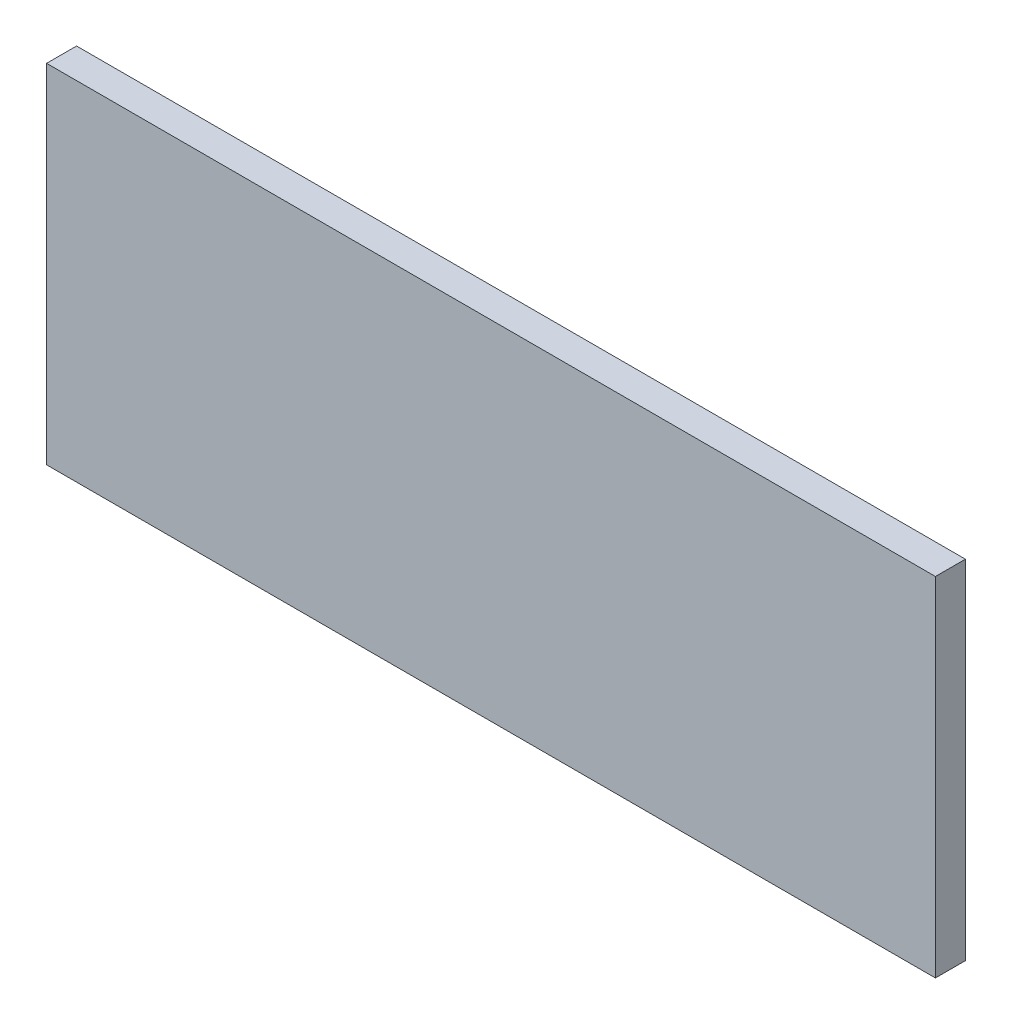
from build123d import *

# Parameters (mm, degrees)
ESBO_O1_W                = 296.5
ESBO_O1_H                = 116
RESSALTO_EXTRUS_O1_DEPTH = 5


with BuildPart() as part:
    # Esboço1 → Ressalto-extrusão1 (new body, symmetric)
    with BuildSketch(Plane.XY):
        Rectangle(ESBO_O1_W, ESBO_O1_H)
    extrude(amount=RESSALTO_EXTRUS_O1_DEPTH, both=True)


solid = part.part
